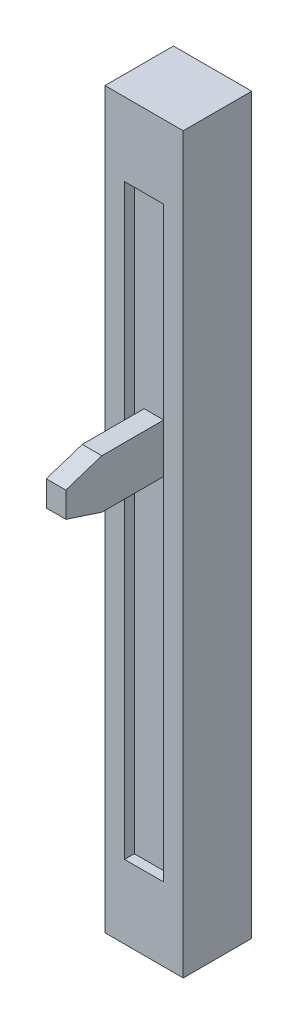
from build123d import *

# Parameters (mm, degrees)
SKETCH1_W           = 8
SKETCH1_H           = 75
BOSS_EXTRUDE1_DEPTH = 7
SKETCH2_W           = 4
SKETCH2_H           = 60
CUT_EXTRUDE1_DEPTH  = 1
BOSS_EXTRUDE2_DEPTH = 1


with BuildPart() as part:
    # Sketch1 → Boss-Extrude1 (new body)
    with BuildSketch(Plane.XY):
        Rectangle(SKETCH1_W, SKETCH1_H)
    extrude(amount=BOSS_EXTRUDE1_DEPTH)

    # Sketch2 → Cut-Extrude1 (cut)
    with BuildSketch(Plane.XY.offset(7)):
        Rectangle(SKETCH2_W, SKETCH2_H)
    extrude(amount=-CUT_EXTRUDE1_DEPTH, mode=Mode.SUBTRACT)

    # Sketch3 → Boss-Extrude2 (add, symmetric)
    with BuildSketch(Plane(origin=(0, 0, 0), x_dir=(0, 0, -1), z_dir=(1, 0, 0))):
        Polygon((-5.362926248, 9.895130651), (-12.32555201, 9.895130651), (-16, 8.689278514), (-16, 6.100982787), (-12.32555201, 4.895130651), (-5.362926248, 4.895130651), align=None)
    extrude(amount=BOSS_EXTRUDE2_DEPTH, both=True)


solid = part.part
